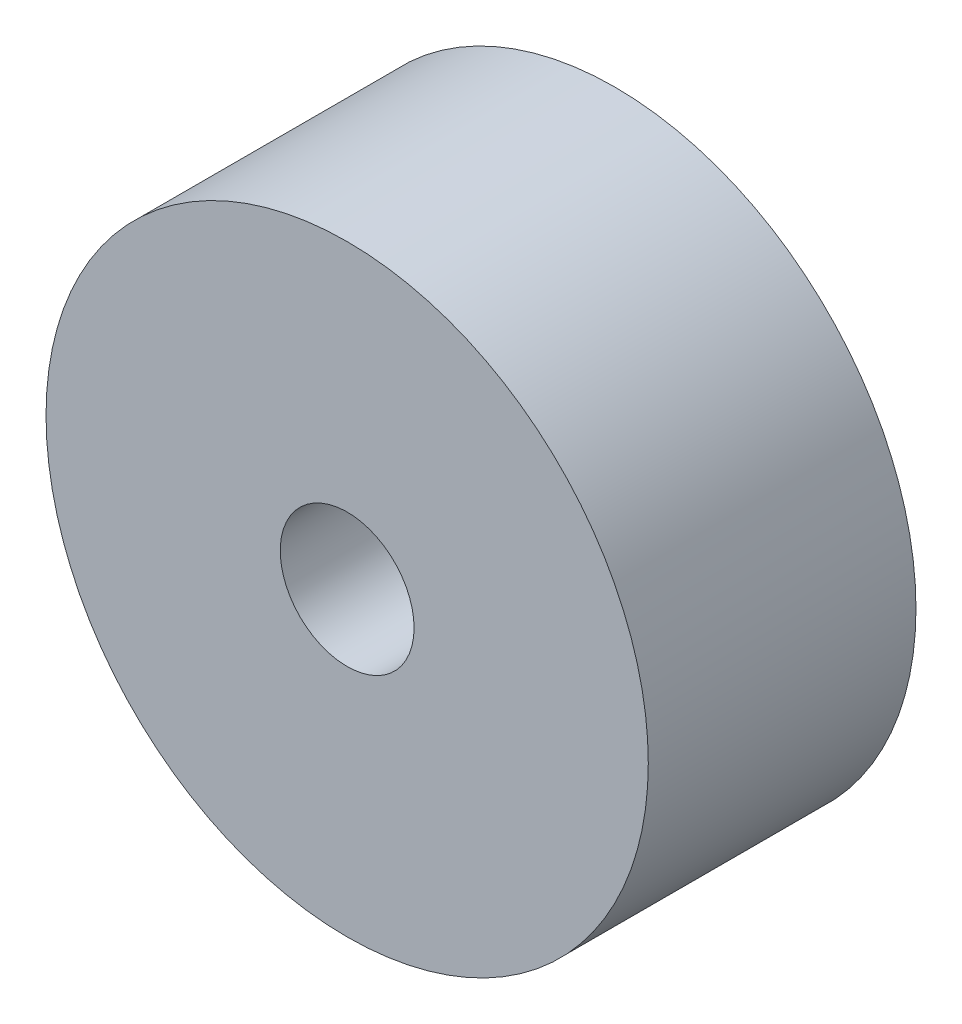
from build123d import *

# Parameters (mm, degrees)
SKETCH1_R           = 22.5
SKETCH1_R_2         = 5
BOSS_EXTRUDE1_DEPTH = 20


with BuildPart() as part:
    # Sketch1 → Boss-Extrude1 (new body)
    with BuildSketch(Plane.XY):
        Circle(SKETCH1_R)
        Circle(SKETCH1_R_2, mode=Mode.SUBTRACT)
    extrude(amount=BOSS_EXTRUDE1_DEPTH)


solid = part.part
